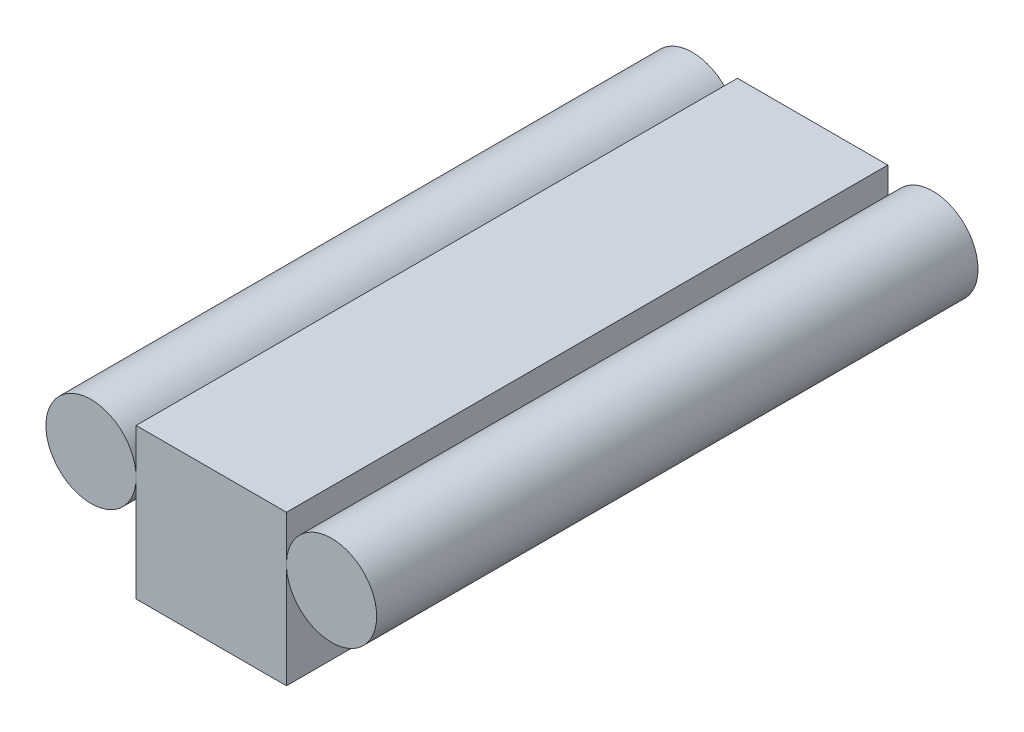
from build123d import *

# Parameters (mm, degrees)
BOSS_EXTRUDE2_DEPTH   = 2000
SKETCH1_R             = 150
BOSS_EXTRUDE2_2_DEPTH = 2000
BOSS_EXTRUDE2_3_DEPTH = 2000


with BuildPart() as part:
    # Sketch1 → Boss-Extrude2 (new body)
    with BuildSketch(Plane.XY):
        Polygon((0, -48.431267813), (0, 101.56873269), (-500, 101.56873269), (-500, -48.43126731), (-500, -398.43126731), (0, -398.43126731), align=None)
    extrude(amount=BOSS_EXTRUDE2_DEPTH)


with BuildPart() as body_2:
    # Sketch1 → Boss-Extrude2 2 (new body)
    with BuildSketch(Plane.XY):
        with Locations((150, -48.43126731)):
            Circle(SKETCH1_R)
    extrude(amount=BOSS_EXTRUDE2_2_DEPTH)


with BuildPart() as body_3:
    # Sketch1 → Boss-Extrude2 3 (new body)
    with BuildSketch(Plane.XY):
        with Locations((-650, -48.43126731)):
            Circle(SKETCH1_R)
    extrude(amount=BOSS_EXTRUDE2_3_DEPTH)


solid = Compound([part.part, body_2.part, body_3.part])
